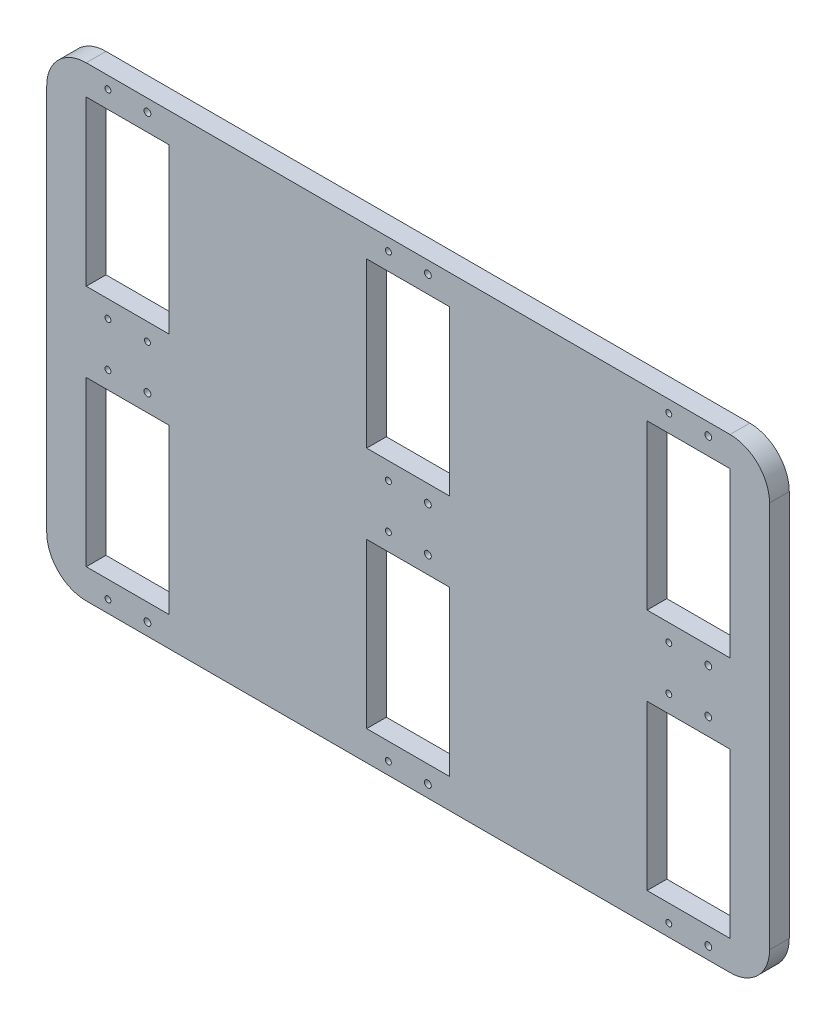
from build123d import *

# Parameters (mm, degrees)
SKETCH1_W           = 183
SKETCH1_H           = 118
SKETCH1_W_2         = 21
SKETCH1_H_2         = 41.5
BOSS_EXTRUDE1_DEPTH = 5
SKETCH2_R           = 0.75
SKETCH2_R_2         = 0.865315656
CUT_EXTRUDE1_DEPTH  = 5
FILLET5_R           = 10
FILLET6_R           = 10
FILLET7_R           = 10
FILLET8_R           = 10


with BuildPart() as part:
    # Sketch1 → Boss-Extrude1 (new body)
    with BuildSketch(Plane.XY):
        with Locations((-91.5, 59)):
            Rectangle(SKETCH1_W, SKETCH1_H)
        with Locations((-162.5, 28.25)):
            Rectangle(SKETCH1_W_2, SKETCH1_H_2, mode=Mode.SUBTRACT)
        with Locations((-91.5, 28.25)):
            Rectangle(SKETCH1_W_2, SKETCH1_H_2, mode=Mode.SUBTRACT)
        with Locations((-20.5, 28.25)):
            Rectangle(SKETCH1_W_2, SKETCH1_H_2, mode=Mode.SUBTRACT)
        with Locations((-162.5, 89.75)):
            Rectangle(SKETCH1_W_2, SKETCH1_H_2, mode=Mode.SUBTRACT)
        with Locations((-91.5, 89.75)):
            Rectangle(SKETCH1_W_2, SKETCH1_H_2, mode=Mode.SUBTRACT)
        with Locations((-20.5, 89.75)):
            Rectangle(SKETCH1_W_2, SKETCH1_H_2, mode=Mode.SUBTRACT)
    extrude(amount=BOSS_EXTRUDE1_DEPTH)

    # Sketch2 → Cut-Extrude1 (cut)
    with BuildSketch(Plane.XY.offset(5)):
        with Locations((-167.5, 114.9)):
            Circle(SKETCH2_R)
        with Locations((-157.5, 114.9)):
            Circle(SKETCH2_R_2)
        with Locations((-167.5, 64.6)):
            Circle(SKETCH2_R)
        with Locations((-157.5, 64.6)):
            Circle(SKETCH2_R)
        with Locations((-96.5, 114.9)):
            Circle(SKETCH2_R)
        with Locations((-86.5, 114.9)):
            Circle(SKETCH2_R_2)
        with Locations((-96.5, 64.6)):
            Circle(SKETCH2_R)
        with Locations((-86.5, 64.6)):
            Circle(SKETCH2_R_2)
        with Locations((-96.5, 53.4)):
            Circle(SKETCH2_R)
        with Locations((-86.5, 53.4)):
            Circle(SKETCH2_R_2)
        with Locations((-25.5, 114.9)):
            Circle(SKETCH2_R)
        with Locations((-15.5, 114.9)):
            Circle(SKETCH2_R_2)
        with Locations((-25.5, 64.6)):
            Circle(SKETCH2_R)
        with Locations((-15.5, 64.6)):
            Circle(SKETCH2_R_2)
        with Locations((-25.5, 53.4)):
            Circle(SKETCH2_R)
        with Locations((-15.5, 53.4)):
            Circle(SKETCH2_R_2)
        with Locations((-25.5, 3.1)):
            Circle(SKETCH2_R)
        with Locations((-15.5, 3.1)):
            Circle(SKETCH2_R_2)
        with Locations((-96.5, 3.1)):
            Circle(SKETCH2_R)
        with Locations((-86.5, 3.1)):
            Circle(SKETCH2_R_2)
        with Locations((-167.5, 3.1)):
            Circle(SKETCH2_R)
        with Locations((-157.5, 3.1)):
            Circle(SKETCH2_R_2)
        with Locations((-167.5, 53.4)):
            Circle(SKETCH2_R)
        with Locations((-157.5, 53.4)):
            Circle(SKETCH2_R_2)
    extrude(amount=-CUT_EXTRUDE1_DEPTH, mode=Mode.SUBTRACT)

    # Fillet5
    fillet5_edges = [part.edges().sort_by_distance(p)[0] for p in [
        (-183, 118, 2.5),
    ]]
    fillet(fillet5_edges, radius=FILLET5_R)

    # Fillet6
    fillet6_edges = [part.edges().sort_by_distance(p)[0] for p in [
        (-183, 0, 2.5),
    ]]
    fillet(fillet6_edges, radius=FILLET6_R)

    # Fillet7
    fillet7_edges = [part.edges().sort_by_distance(p)[0] for p in [
        (0, 118, 2.5),
    ]]
    fillet(fillet7_edges, radius=FILLET7_R)

    # Fillet8
    fillet8_edges = [part.edges().sort_by_distance(p)[0] for p in [
        (0, 0, 2.5),
    ]]
    fillet(fillet8_edges, radius=FILLET8_R)


solid = part.part
